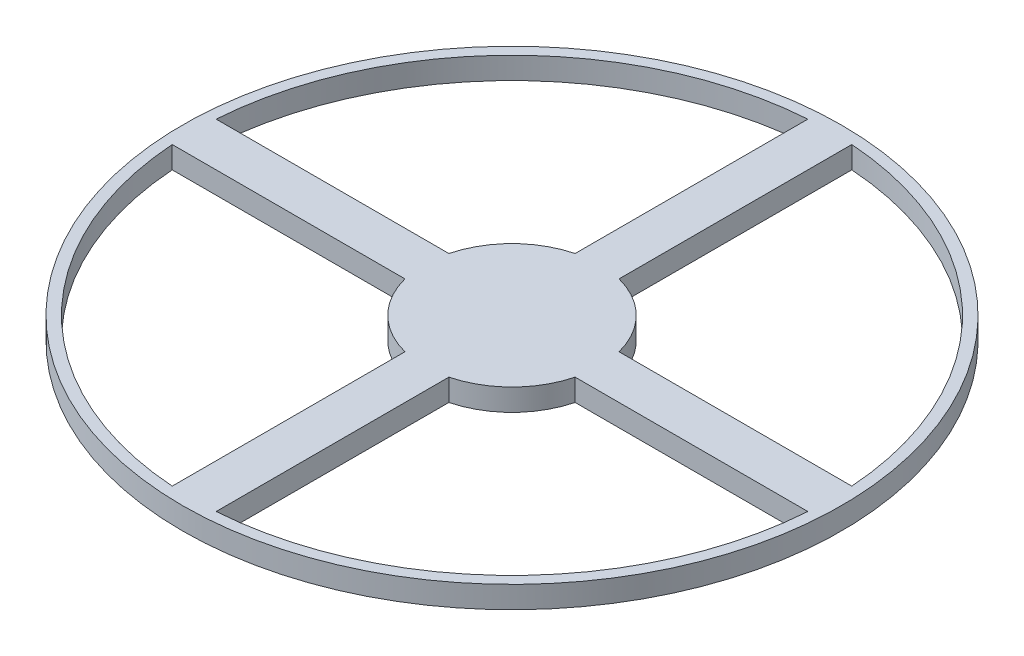
from build123d import *

# Parameters (mm, degrees)
BEAM_DEPTH        = 6.35
CENTER_R          = 25.4
CENTER1_DEPTH     = 6.35
RING_R            = 95.25
RING_R_2          = 92.075
RING1_DEPTH       = 6.35
CIRPATTERN3_COUNT = 4


with BuildPart() as part:
    # Beams → Beam (new body)
    with BuildSketch(Plane(origin=(0, 0, 0), x_dir=(1, 0, 0), z_dir=(0, 1, 0))):
        with BuildLine():
            Line((-91.855773498, 6.35), (-24.593444248, 6.35))
            ThreePointArc((-24.593444248, 6.35), (-25.4, 0), (-24.593444248, -6.35))
            Line((-24.593444248, -6.35), (-91.855773498, -6.35))
            ThreePointArc((-91.855773498, -6.35), (-92.075, 0), (-91.855773498, 6.35))
        make_face()
    beam = extrude(amount=BEAM_DEPTH)

    # Center → Center1 (add)
    with BuildSketch(Plane(origin=(0, 0, 0), x_dir=(1, 0, 0), z_dir=(0, 1, 0))):
        Circle(CENTER_R)
    extrude(amount=CENTER1_DEPTH)

    # Ring → Ring1 (add)
    with BuildSketch(Plane(origin=(0, 0, 0), x_dir=(1, 0, 0), z_dir=(0, 1, 0))):
        Circle(RING_R)
        Circle(RING_R_2, mode=Mode.SUBTRACT)
    extrude(amount=RING1_DEPTH)

    # CirPattern3: Beam ×4 about axis
    cirpattern3_axis = Axis((0, 0, 0), (0, 1, 0))
    for i in range(1, CIRPATTERN3_COUNT):
        add(beam.rotate(cirpattern3_axis, i * 360 / CIRPATTERN3_COUNT))


solid = part.part
